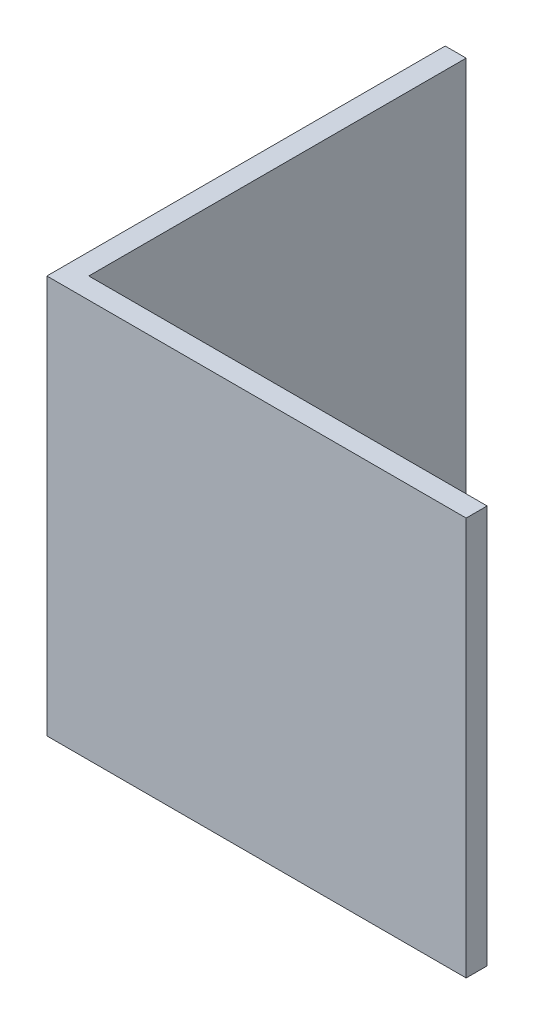
from build123d import *

# Parameters (mm, degrees)
EXTRUDE_1_DEPTH    = 19
SKETCH1_W          = 1
SKETCH1_H          = 19
CUT_EXTRUDE1_DEPTH = 1


with BuildPart() as part:
    # Эскиз1 → Бобышка-Вытянуть1 (new body)
    with BuildSketch(Plane(origin=(0, 0, 0), x_dir=(1, 0, 0), z_dir=(0, 1, 0))):
        Polygon((0, 0), (0, 20), (1, 20), (1, 1), (20, 1), (20, 0), align=None)
    extrude(amount=EXTRUDE_1_DEPTH)

    # Sketch1 → Cut-Extrude1 (cut)
    with BuildSketch(Plane(origin=(0, 0, -20), x_dir=(-1, 0, 0), z_dir=(0, 0, -1))):
        with Locations((-0.5, 9.5)):
            Rectangle(SKETCH1_W, SKETCH1_H)
    extrude(amount=-CUT_EXTRUDE1_DEPTH, mode=Mode.SUBTRACT)


solid = part.part
